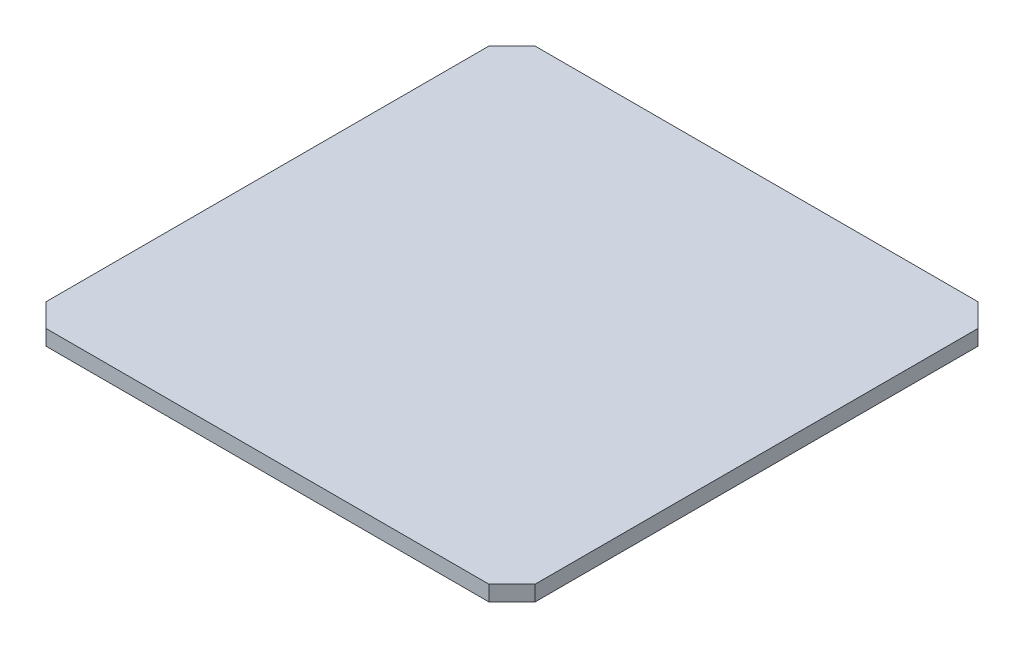
from build123d import *

# Parameters (mm, degrees)
ESQUISSE1_W        = 25.4
ESQUISSE1_H        = 25.4
BOSS_EXTRU_1_DEPTH = 0.8
CHANFREIN1_SIZE    = 1.2


with BuildPart() as part:
    # Esquisse1 → Boss.-Extru.1 (new body)
    with BuildSketch(Plane(origin=(0, 0, 0), x_dir=(1, 0, 0), z_dir=(0, 1, 0))):
        with Locations((12.7, 12.7)):
            Rectangle(ESQUISSE1_W, ESQUISSE1_H)
    extrude(amount=BOSS_EXTRU_1_DEPTH)

    # Chanfrein1
    chanfrein1_edges = [part.edges().sort_by_distance(p)[0] for p in [
        (0, 0.4, -25.4),
        (25.4, 0.4, -25.4),
        (25.4, 0.4, 0),
        (0, 0.4, 0),
    ]]
    chamfer(chanfrein1_edges, length=CHANFREIN1_SIZE)


solid = part.part
